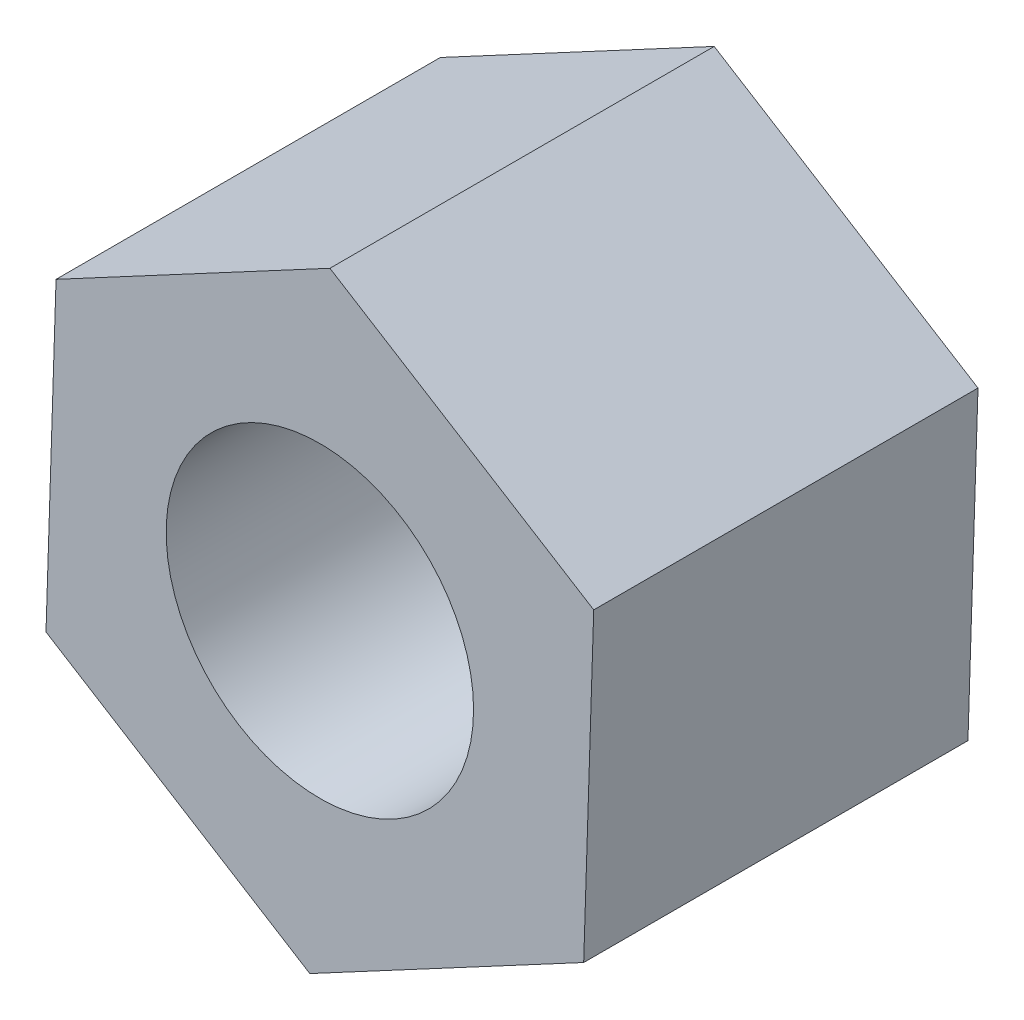
from build123d import *

# Parameters (mm, degrees)
SKETCH1_R      = 3.175
EXTRUDE1_DEPTH = 7.9375


with BuildPart() as part:
    # Sketch1 → Extrude1 (new body)
    with BuildSketch(Plane.XY):
        Polygon((5.657191877, 3.026339728), (0.207708854, 6.412441744), (-5.449483023, 3.386102016), (-5.657191877, -3.026339728), (-0.207708854, -6.412441744), (5.449483023, -3.386102016), align=None)
        Circle(SKETCH1_R, mode=Mode.SUBTRACT)
    extrude(amount=EXTRUDE1_DEPTH)


solid = part.part
